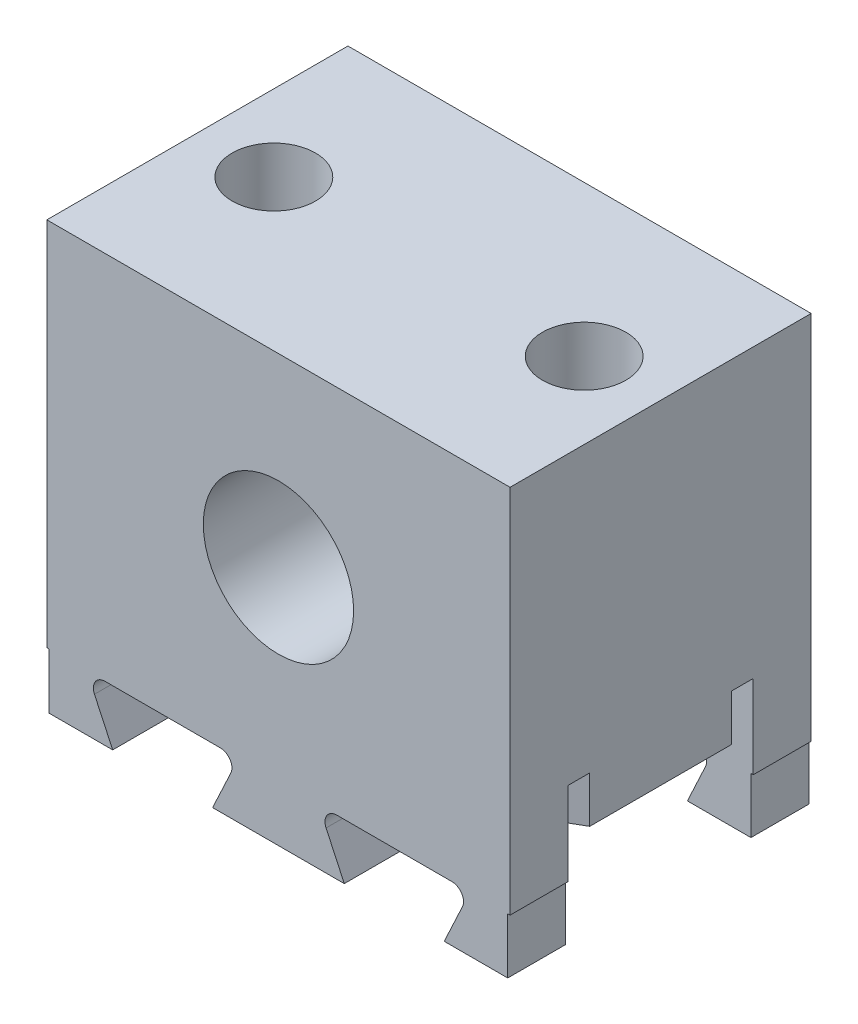
from build123d import *

# Parameters (mm, degrees)
SKETCH1_W           = 20
SKETCH1_H           = 16
BOSS_EXTRUDE1_DEPTH = 13
SKETCH2_W           = 20
SKETCH2_H           = 8
CUT_EXTRUDE1_DEPTH  = 3.6
SKETCH3_R           = 1.8
CUT_EXTRUDE2_DEPTH  = 17
BOSS_EXTRUDE2_DEPTH = 2
BOSS_EXTRUDE3_DEPTH = 13
SKETCH7_W           = 20
SKETCH7_H           = 8
CUT_EXTRUDE3_DEPTH  = 4
FILLET1_R           = 0.5
SKETCH8_R           = 3.245
CUT_EXTRUDE4_DEPTH  = 14.0000001


with BuildPart() as part:
    # Sketch1 → Boss-Extrude1 (new body)
    with BuildSketch(Plane.XY):
        with Locations((10, 8)):
            Rectangle(SKETCH1_W, SKETCH1_H)
    extrude(amount=BOSS_EXTRUDE1_DEPTH)

    # Sketch2 → Cut-Extrude1 (cut)
    with BuildSketch(Plane.XZ):
        with Locations((10, 6.5)):
            Rectangle(SKETCH2_W, SKETCH2_H)
    extrude(amount=-CUT_EXTRUDE1_DEPTH, mode=Mode.SUBTRACT)

    # Sketch3 → Cut-Extrude2 (cut, through all)
    with BuildSketch(Plane(origin=(0, 16, 0), x_dir=(1, 0, 0), z_dir=(0, 1, 0))):
        with Locations((3.3, -6.5)):
            Circle(SKETCH3_R)
        with Locations((16.7, -6.5)):
            Circle(SKETCH3_R)
    extrude(amount=-CUT_EXTRUDE2_DEPTH, mode=Mode.SUBTRACT)

    # Sketch4 → Boss-Extrude2 (add)
    with BuildSketch(Plane.XZ.offset(-3.6)):
        Polygon((7.601093671, 8.983237589), (4.973984112, 10.5), (1.626015888, 10.5), (0, 9.561219289), (0, 3.438780711), (1.626015888, 2.5), (4.973984112, 2.5), (7.601093671, 4.016762411), align=None)
        Polygon((0.498906329, 8.117212185), (3.3, 9.73442437), (6.101093671, 8.117212185), (6.101093671, 4.882787815), (3.3, 3.26557563), (0.498906329, 4.882787815), align=None, mode=Mode.SUBTRACT)
        Polygon((18.373984112, 10.5), (15.026015888, 10.5), (12.398906329, 8.983237589), (12.398906329, 4.016762411), (15.026015888, 2.5), (18.373984112, 2.5), (20, 3.438780711), (20, 9.561219289), align=None)
        Polygon((13.898906329, 8.117212185), (16.7, 9.73442437), (19.501093671, 8.117212185), (19.501093671, 4.882787815), (16.7, 3.26557563), (13.898906329, 4.882787815), align=None, mode=Mode.SUBTRACT)
    extrude(amount=BOSS_EXTRUDE2_DEPTH)

    # Sketch6 → Boss-Extrude3 (add)
    with BuildSketch(Plane.XY.offset(13)):
        Polygon((0.1, 0), (0.1, -2.4), (2.843031442, -2.4), (1.743600076, -0.042261826), (1.723893063, 0), align=None)
        Polygon((12.843031442, -2.4), (11.743600076, -0.042261826), (11.723893063, 0), (8.276106937, 0), (8.256399924, -0.042261826), (7.156968558, -2.4), align=None)
        Polygon((19.9, -2.4), (19.9, 0), (18.276106937, 0), (18.256399924, -0.042261826), (17.156968558, -2.4), align=None)
    extrude(amount=-BOSS_EXTRUDE3_DEPTH)

    # Sketch7 → Cut-Extrude3 (cut)
    with BuildSketch(Plane.XZ.offset(2.4)):
        with Locations((10, 6.5)):
            Rectangle(SKETCH7_W, SKETCH7_H)
    extrude(amount=-CUT_EXTRUDE3_DEPTH, mode=Mode.SUBTRACT)

    # Fillet1
    fillet1_edges = [part.edges().sort_by_distance(p)[0] for p in [
        (1.723893063, 0, 1.25),
        (1.723893063, 0, 11.75),
        (8.276106937, 0, 1.25),
        (11.723893063, 0, 1.25),
        (11.723893063, 0, 11.75),
        (8.276106937, 0, 11.75),
        (18.276106937, 0, 1.25),
        (18.276106937, 0, 11.75),
    ]]
    fillet(fillet1_edges, radius=FILLET1_R)

    # Sketch8 → Cut-Extrude4 (cut, through all)
    with BuildSketch(Plane.XY.offset(13)):
        with Locations((10, 8)):
            Circle(SKETCH8_R)
    extrude(amount=-CUT_EXTRUDE4_DEPTH, mode=Mode.SUBTRACT)


solid = part.part
